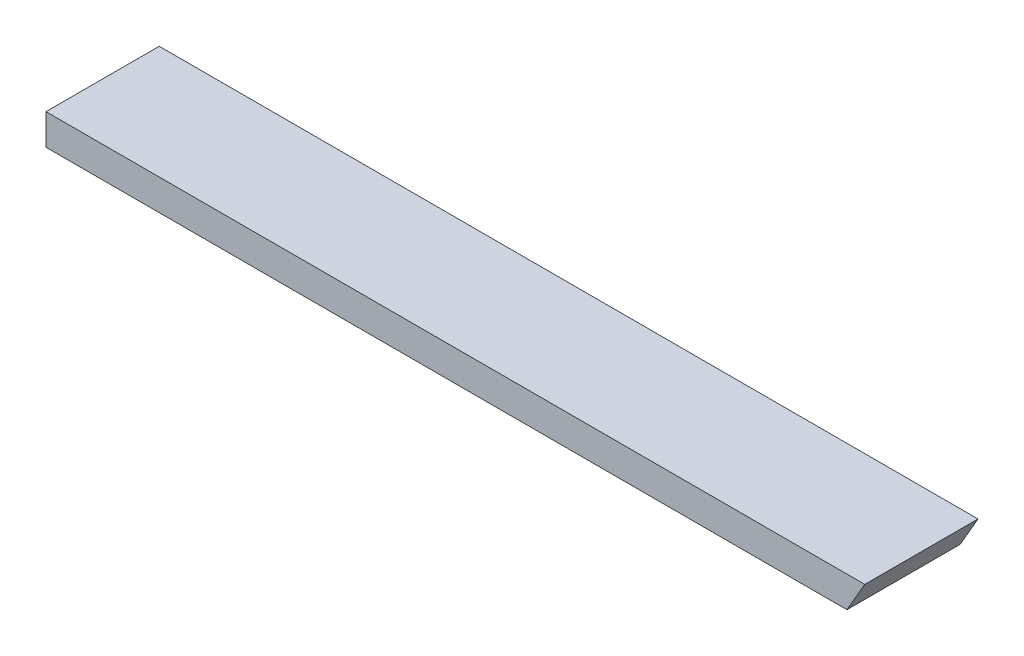
from build123d import *

# Parameters (mm, degrees)
SKETCH1_W               = 1066.8
SKETCH1_H               = 139.7
BOSS_EXTRUDE1_DEPTH     = 38.1
CUT_EXTRUDE1_DEPTH      = 1
CUT_EXTRUDE1_DEPTH_BACK = 140.7


with BuildPart() as part:
    # Sketch1 → Boss-Extrude1 (new body)
    with BuildSketch(Plane(origin=(0, 0, 0), x_dir=(1, 0, 0), z_dir=(0, 1, 0))):
        with Locations((533.4, 69.85)):
            Rectangle(SKETCH1_W, SKETCH1_H)
    extrude(amount=BOSS_EXTRUDE1_DEPTH)

    # Sketch2 → Cut-Extrude1 (cut, two sides)
    with BuildSketch(Plane(origin=(0, 0, -139.7), x_dir=(-1, 0, 0), z_dir=(0, 0, -1))) as cut_extrude1_sk:
        Polygon((27.715210153, -1759.759205787), (-988.282241017, 0), (-1010.279286273, 38.1), (-2026.276737443, 1797.859205787), (-5545.795149018, -234.135696553), (-3491.803201422, -3791.754108128), align=None)
    extrude(amount=CUT_EXTRUDE1_DEPTH, mode=Mode.SUBTRACT)
    extrude(cut_extrude1_sk.sketch, amount=-CUT_EXTRUDE1_DEPTH_BACK, mode=Mode.SUBTRACT)


solid = part.part
